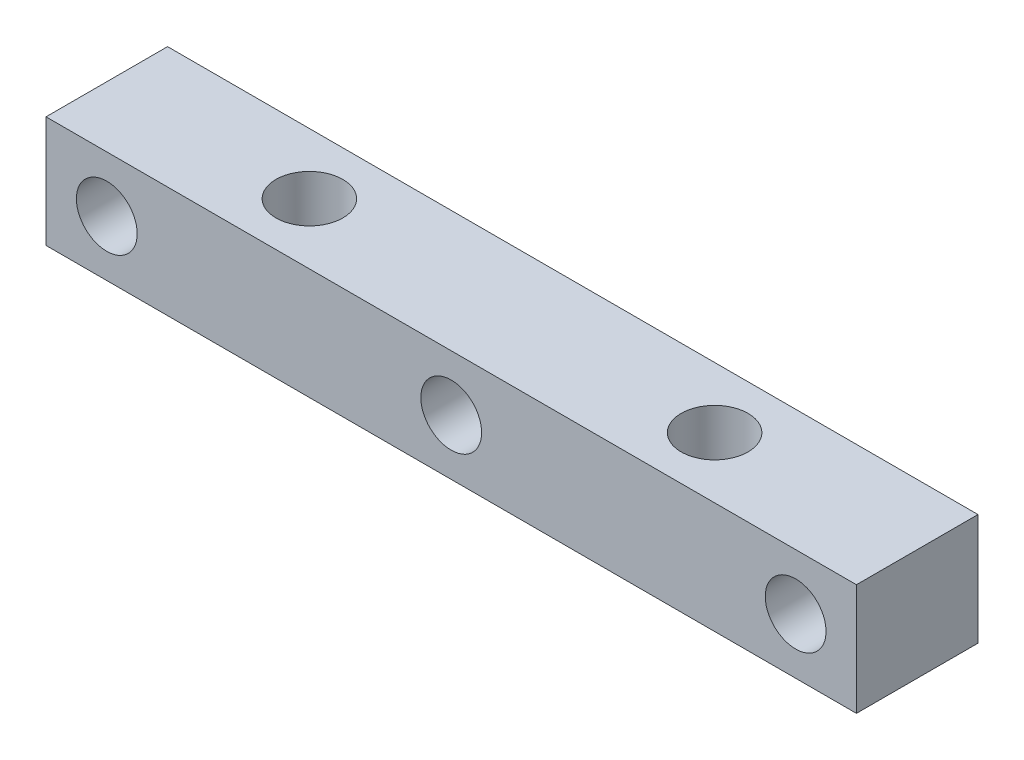
from build123d import *

# Parameters (mm, degrees)
ESQUISSE1_W                  = 40
ESQUISSE1_H                  = 5.5
BOSS_EXTRU_1_DEPTH           = 6
ESQUISSE2_R                  = 1.5
ENL_V_MAT_EXTRU_1_DEPTH      = 1
ENL_V_MAT_EXTRU_1_DEPTH_BACK = 7
ESQUISSE3_R                  = 1.65
ENL_V_MAT_EXTRU_2_DEPTH      = 1
ENL_V_MAT_EXTRU_2_DEPTH_BACK = 6.5


with BuildPart() as part:
    # Esquisse1 → Boss.-Extru.1 (new body)
    with BuildSketch(Plane.XY):
        with Locations((20, 2.75)):
            Rectangle(ESQUISSE1_W, ESQUISSE1_H)
    extrude(amount=BOSS_EXTRU_1_DEPTH)

    # Esquisse2 → Enlèv. mat.-Extru.1 (cut, two sides)
    with BuildSketch(Plane.XY.offset(6)) as enl_v_mat_extru_1_sk:
        with Locations((20, 2.75)):
            Circle(ESQUISSE2_R)
        with Locations((3, 2.75)):
            Circle(ESQUISSE2_R)
        with Locations((37, 2.75)):
            Circle(ESQUISSE2_R)
    extrude(amount=ENL_V_MAT_EXTRU_1_DEPTH, mode=Mode.SUBTRACT)
    extrude(enl_v_mat_extru_1_sk.sketch, amount=-ENL_V_MAT_EXTRU_1_DEPTH_BACK, mode=Mode.SUBTRACT)

    # Esquisse3 → Enlèv. mat.-Extru.2 (cut, two sides)
    with BuildSketch(Plane(origin=(0, 5.5, 0), x_dir=(1, 0, 0), z_dir=(0, 1, 0))) as enl_v_mat_extru_2_sk:
        with Locations((10, -3)):
            Circle(ESQUISSE3_R)
        with Locations((30, -3)):
            Circle(ESQUISSE3_R)
    extrude(amount=ENL_V_MAT_EXTRU_2_DEPTH, mode=Mode.SUBTRACT)
    extrude(enl_v_mat_extru_2_sk.sketch, amount=-ENL_V_MAT_EXTRU_2_DEPTH_BACK, mode=Mode.SUBTRACT)


solid = part.part
